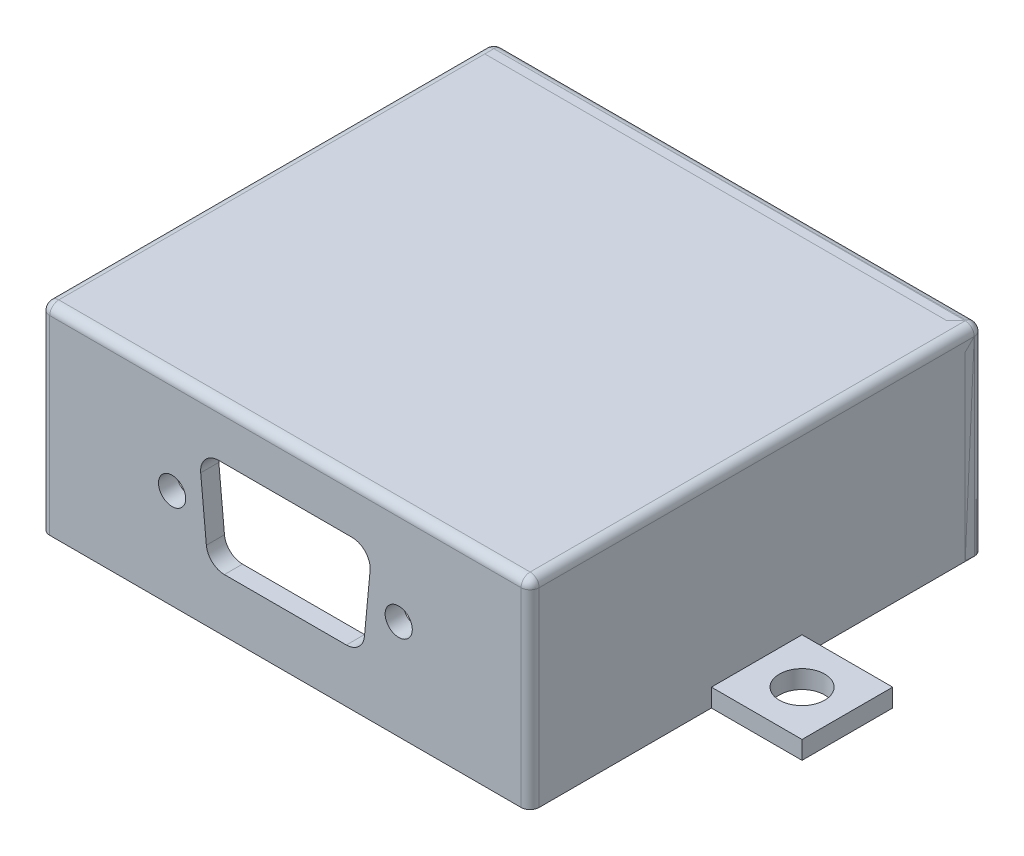
from build123d import *

# Parameters (mm, degrees)
SKETCH1_W           = 50
SKETCH1_H           = 20
SKETCH1_R           = 1.5
BOSS_EXTRUDE1_DEPTH = 2
BOSS_EXTRUDE3_DEPTH = 50
SKETCH4_W           = 54
SKETCH4_H           = 22
SKETCH4_R           = 5
BOSS_EXTRUDE4_DEPTH = 2
SKETCH5_W           = 10
SKETCH5_H           = 2
BOSS_EXTRUDE5_DEPTH = 5
FILLET1_R           = 1
FILLET2_R           = 1
SKETCH6_R           = 2.5
CUT_EXTRUDE1_DEPTH  = 2


with BuildPart() as part:
    # Sketch1 → Boss-Extrude1 (new body)
    with BuildSketch(Plane.XY):
        with Locations((25, 10)):
            Rectangle(SKETCH1_W, SKETCH1_H)
        with Locations((12.497693795, 11.000889914)):
            Circle(SKETCH1_R, mode=Mode.SUBTRACT)
        with Locations((37.502306205, 11.000889914)):
            Circle(SKETCH1_R, mode=Mode.SUBTRACT)
        with BuildLine():
            Line((17.647559495, 16.488444137), (32.352440505, 16.488444137))
            ThreePointArc((32.352440505, 16.488444137), (33.831577141, 15.834607133), (34.34359951, 14.300598948))
            Line((34.34359951, 14.300598948), (33.7210129, 7.701180879))
            ThreePointArc((33.7210129, 7.701180879), (33.07601689, 6.409889432), (31.729853895, 5.889026069))
            Line((31.729853895, 5.889026069), (18.270146105, 5.889026069))
            ThreePointArc((18.270146105, 5.889026069), (16.92398311, 6.409889432), (16.2789871, 7.701180879))
            Line((16.2789871, 7.701180879), (15.65640049, 14.300598948))
            ThreePointArc((15.65640049, 14.300598948), (16.168422859, 15.834607133), (17.647559495, 16.488444137))
        make_face(mode=Mode.SUBTRACT)
    extrude(amount=BOSS_EXTRUDE1_DEPTH)

    # Sketch2 → Boss-Extrude3 (add)
    with BuildSketch(Plane.XY.offset(2)):
        Polygon((50, 0), (52, 0), (52, 22), (-2, 22), (-2, 0), (0, 0), (0, 20), (50, 20), align=None)
    extrude(amount=-BOSS_EXTRUDE3_DEPTH)

    # Sketch5 → Boss-Extrude5 (add, symmetric)
    with BuildSketch(Plane.XY.offset(-23)):
        with Locations((-7, 1)):
            Rectangle(SKETCH5_W, SKETCH5_H)
        with Locations((57, 1)):
            Rectangle(SKETCH5_W, SKETCH5_H)
    extrude(amount=BOSS_EXTRUDE5_DEPTH, both=True)

    # Fillet1
    fillet1_edges = [part.edges().sort_by_distance(p)[0] for p in [
        (-2, 11, 2),
        (25, 22, 2),
        (-2, 22, -23),
        (52, 11, -48),
        (52, 22, -23),
        (-2, 11, -48),
        (25, 22, -48),
        (52, 11, 2),
    ]]
    fillet(fillet1_edges, radius=FILLET1_R)

    # Sketch6 → Cut-Extrude1 (cut)
    with BuildSketch(Plane(origin=(0, 2, 0), x_dir=(1, 0, 0), z_dir=(0, 1, 0))):
        with Locations((-7, 23)):
            Circle(SKETCH6_R)
        with Locations((57, 23)):
            Circle(SKETCH6_R)
    extrude(amount=-CUT_EXTRUDE1_DEPTH, mode=Mode.SUBTRACT)


with BuildPart() as body_2:
    # Sketch4 → Boss-Extrude4 (new body)
    with BuildSketch(Plane(origin=(0, 0, -48), x_dir=(-1, 0, 0), z_dir=(0, 0, -1))):
        with Locations((-25, 11)):
            Rectangle(SKETCH4_W, SKETCH4_H)
        with Locations((-24, 10)):
            Circle(SKETCH4_R, mode=Mode.SUBTRACT)
    extrude(amount=-BOSS_EXTRUDE4_DEPTH)

    # Fillet2
    fillet2_edges = [body_2.edges().sort_by_distance(p)[0] for p in [
        (25, 22, -48),
        (-2, 11, -48),
        (25, 0, -48),
        (52, 11, -48),
        (52, 22, -47),
        (-2, 22, -47),
    ]]
    fillet(fillet2_edges, radius=FILLET2_R)


solid = Compound([part.part, body_2.part])
